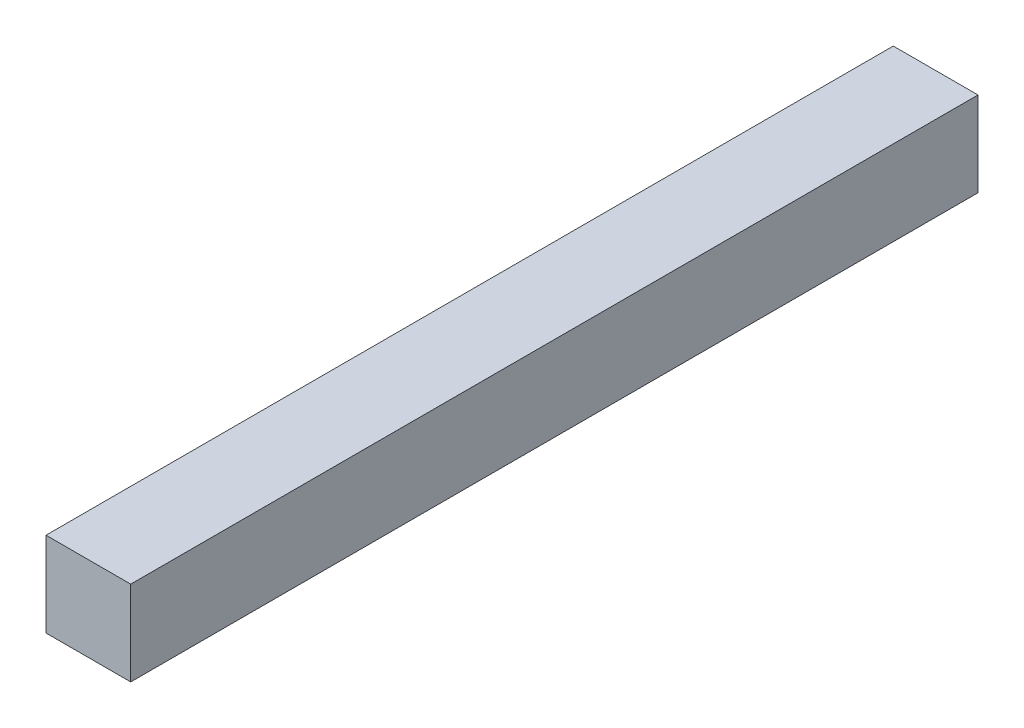
from build123d import *

# Parameters (mm, degrees)
SKETCH1_W           = 10
SKETCH1_H           = 10
BOSS_EXTRUDE1_DEPTH = 205
SKETCH2_R           = 3.5
BOSS_EXTRUDE2_DEPTH = 8
SKETCH4_W           = 18.766575586
SKETCH4_H           = 10.499405733
CUT_EXTRUDE1_DEPTH  = 105


with BuildPart() as part:
    # Sketch1 → Boss-Extrude1 (new body)
    with BuildSketch(Plane.XY):
        with Locations((5, -5)):
            Rectangle(SKETCH1_W, SKETCH1_H)
    extrude(amount=BOSS_EXTRUDE1_DEPTH)

    # Sketch2 → Boss-Extrude2 (add)
    with BuildSketch(Plane(origin=(10, 0, 0), x_dir=(0, 0, -1), z_dir=(1, 0, 0))):
        with Locations((-200, -5.053950804)):
            Circle(SKETCH2_R)
    extrude(amount=BOSS_EXTRUDE2_DEPTH)

    # Sketch4 → Cut-Extrude1 (cut)
    with BuildSketch(Plane.XY.offset(205)):
        with Locations((9.383287793, -4.750297134)):
            Rectangle(SKETCH4_W, SKETCH4_H)
    extrude(amount=-CUT_EXTRUDE1_DEPTH, mode=Mode.SUBTRACT)


solid = part.part
